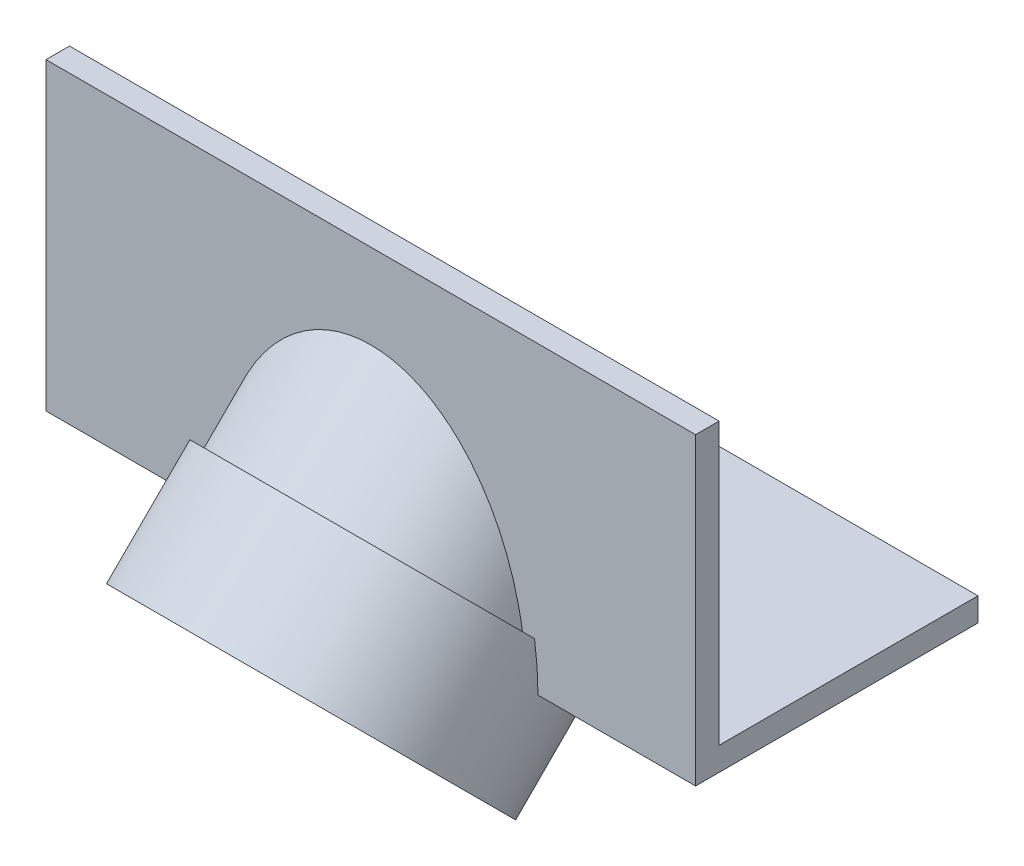
from build123d import *
from build123d.topology import SkipClean

# Parameters (mm, degrees)
BOSS_EXTRUDE1_DEPTH = 27.60218
SKETCH3_R           = 7.1
SKETCH3_R_2         = 5.1
BOSS_EXTRUDE2_DEPTH = 5
SKETCH4_R           = 6.6
SKETCH4_R_2         = 5.6
BOSS_EXTRUDE3_DEPTH = 7.62
CUT_EXTRUDE1_START  = -7.62
SKETCH5_R           = 5.6
CUT_EXTRUDE1_DEPTH  = 7.62
SKETCH6_R           = 5.1
CUT_EXTRUDE2_DEPTH  = 19.05


with BuildPart() as part:
    # Sketch1 → Boss-Extrude1 (new body)
    with BuildSketch(Plane(origin=(0, 0, 0), x_dir=(0, 0, -1), z_dir=(1, 0, 0))):
        Polygon((-11.058823529, 7.635882353), (-11.058823529, -5.294117647), (0.941176471, -5.294117647), (0.941176471, -4.294117647), (-10.058823529, -4.294117647), (-10.058823529, 7.635882353), align=None)
    extrude(amount=BOSS_EXTRUDE1_DEPTH)

    # Sketch3 → Boss-Extrude2 (add)
    with BuildSketch(Plane(origin=(0, -7.176470588, 7.176470588), x_dir=(-1, 0, 0), z_dir=(0, 0.7071067811865465, -0.7071067811865487))):
        with Locations((-13.80109, 4.076262621)):
            Circle(SKETCH3_R)
        with Locations((-13.80109, 4.076262621)):
            Circle(SKETCH3_R_2, mode=Mode.SUBTRACT)
    extrude(amount=-BOSS_EXTRUDE2_DEPTH)

    # Sketch4 → Boss-Extrude3 (add)
    with BuildSketch(Plane(origin=(0, -7.176470588, 7.176470588), x_dir=(-1, 0, 0), z_dir=(0, 0.7071067811865465, -0.7071067811865487))):
        with Locations((-13.80109, 4.076262621)):
            Circle(SKETCH4_R)
        with Locations((-13.80109, 4.076262621)):
            Circle(SKETCH4_R_2, mode=Mode.SUBTRACT)
    extrude(amount=BOSS_EXTRUDE3_DEPTH)

    # Sketch5 → Cut-Extrude1 (cut)
    with SkipClean():  # the faces are left unmerged after this step: merging them gives an invalid solid
        with BuildSketch(Plane(origin=(0, -1.788316916, 1.788316916), x_dir=(1, 0, 0), z_dir=(0, 0.7071067811865465, -0.7071067811865486)).offset(CUT_EXTRUDE1_START)):
            with Locations((13.80109, -4.076262621)):
                Circle(SKETCH5_R)
        extrude(amount=CUT_EXTRUDE1_DEPTH, mode=Mode.SUBTRACT)

    # Sketch6 → Cut-Extrude2 (cut)
    with SkipClean():  # the faces are left unmerged after this step: merging them gives an invalid solid
        with BuildSketch(Plane(origin=(0, -1.788316916, 1.788316916), x_dir=(1, 0, 0), z_dir=(0, 0.7071067811865465, -0.7071067811865486))):
            with Locations((13.80109, -4.076262621)):
                Circle(SKETCH6_R)
        extrude(amount=-CUT_EXTRUDE2_DEPTH, mode=Mode.SUBTRACT)


solid = part.part
